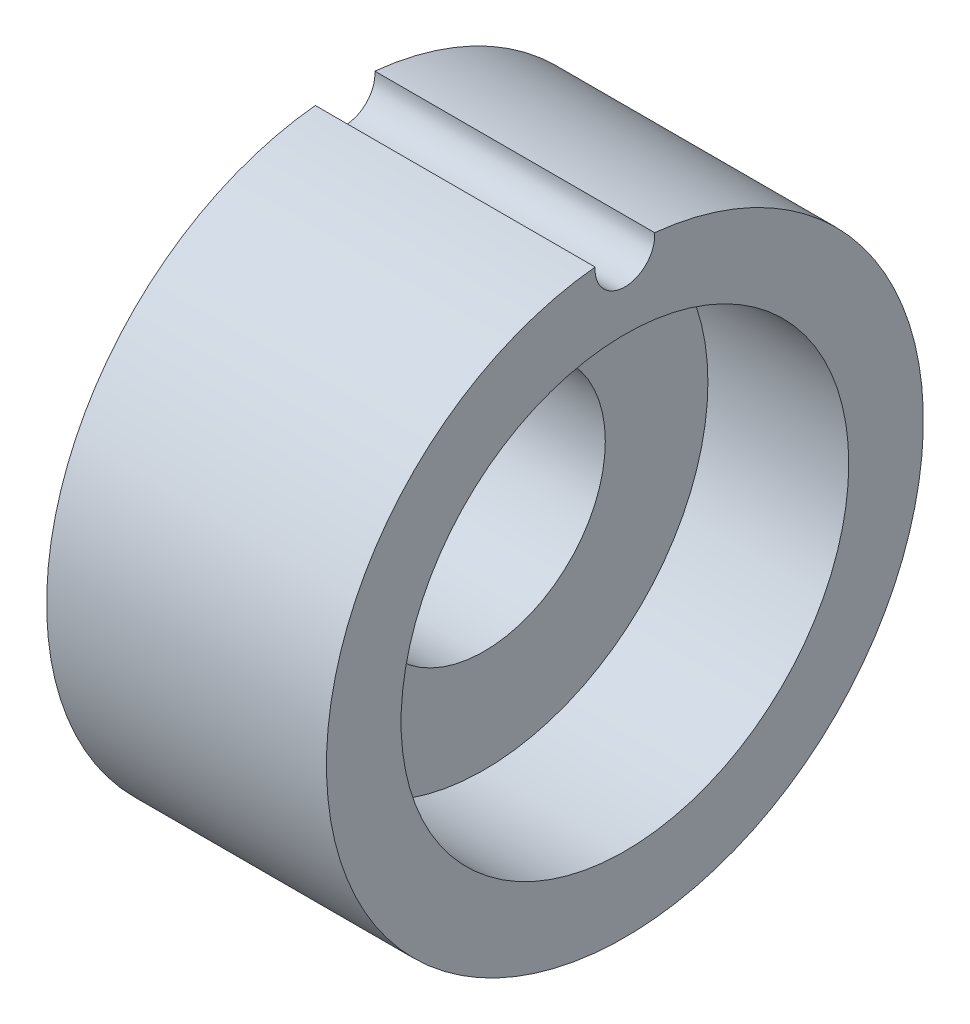
from build123d import *

# Parameters (mm, degrees)
SKETCH2_R           = 8
SKETCH2_R_2         = 3.25
BOSS_EXTRUDE1_DEPTH = 7.5
SKETCH3_R           = 6
CUT_EXTRUDE1_DEPTH  = 3.775
SKETCH4_R           = 0.8
CUT_EXTRUDE2_DEPTH  = 10


with BuildPart() as part:
    # Sketch2 → Boss-Extrude1 (new body)
    with BuildSketch(Plane(origin=(0, 0, 0), x_dir=(0, 0, -1), z_dir=(1, 0, 0))):
        Circle(SKETCH2_R)
        Circle(SKETCH2_R_2, mode=Mode.SUBTRACT)
    extrude(amount=BOSS_EXTRUDE1_DEPTH)

    # Sketch3 → Cut-Extrude1 (cut)
    with BuildSketch(Plane(origin=(7.5, 0, 0), x_dir=(0, 0, -1), z_dir=(1, 0, 0))):
        Circle(SKETCH3_R)
    extrude(amount=-CUT_EXTRUDE1_DEPTH, mode=Mode.SUBTRACT)

    # Sketch4 → Cut-Extrude2 (cut)
    with BuildSketch(Plane(origin=(7.5, 0, 0), x_dir=(0, 0, -1), z_dir=(1, 0, 0))):
        with Locations((0, 7.9)):
            Circle(SKETCH4_R)
    extrude(amount=-CUT_EXTRUDE2_DEPTH, mode=Mode.SUBTRACT)


solid = part.part
